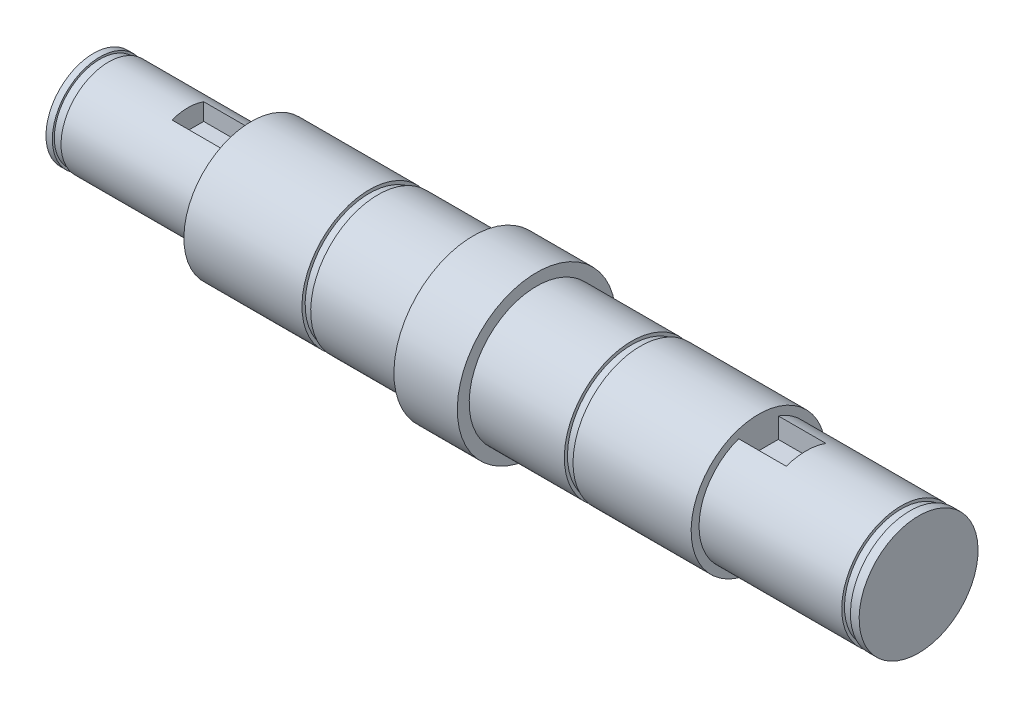
from build123d import *

# Parameters (mm, degrees)
SKETCH2_W          = 4
SKETCH2_H          = 2.5
CUT_EXTRUDE1_DEPTH = 8
SKETCH3_W          = 5
SKETCH3_H          = 3
CUT_EXTRUDE2_DEPTH = 6


with BuildPart() as part:
    # Sketch1 → Revolve1 (revolve)
    with BuildSketch(Plane.XY):
        Polygon((-52.05, 0), (52.05, 0), (52.05, 7.5), (50.95, 7.5), (50.95, 7.15), (49.85, 7.15), (49.85, 7.5), (31.85, 7.5), (31.85, 8.5), (16.95, 8.5), (16.95, 8.1), (15.85, 8.1), (15.85, 8.5), (3.85, 8.5), (3.85, 10), (-4.15, 10), (-4.15, 8.5), (-16.15, 8.5), (-16.15, 8.1), (-17.25, 8.1), (-17.25, 8.5), (-32.15, 8.5), (-32.15, 6), (-50.15, 6), (-50.15, 5.75), (-51.25, 5.75), (-51.25, 6), (-52.05, 6), align=None)
    revolve(axis=Axis((-52.05, 0, 0), (1, 0, 0)))

    # Sketch2 → Cut-Extrude1 (cut)
    with BuildSketch(Plane.ZY.offset(32.15)):
        with Locations((0, 4.75)):
            Rectangle(SKETCH2_W, SKETCH2_H)
    extrude(amount=CUT_EXTRUDE1_DEPTH, mode=Mode.SUBTRACT)

    # Sketch3 → Cut-Extrude2 (cut)
    with BuildSketch(Plane(origin=(31.85, 0, 0), x_dir=(0, 0, -1), z_dir=(1, 0, 0))):
        with Locations((0, 6)):
            Rectangle(SKETCH3_W, SKETCH3_H)
    extrude(amount=CUT_EXTRUDE2_DEPTH, mode=Mode.SUBTRACT)


solid = part.part
